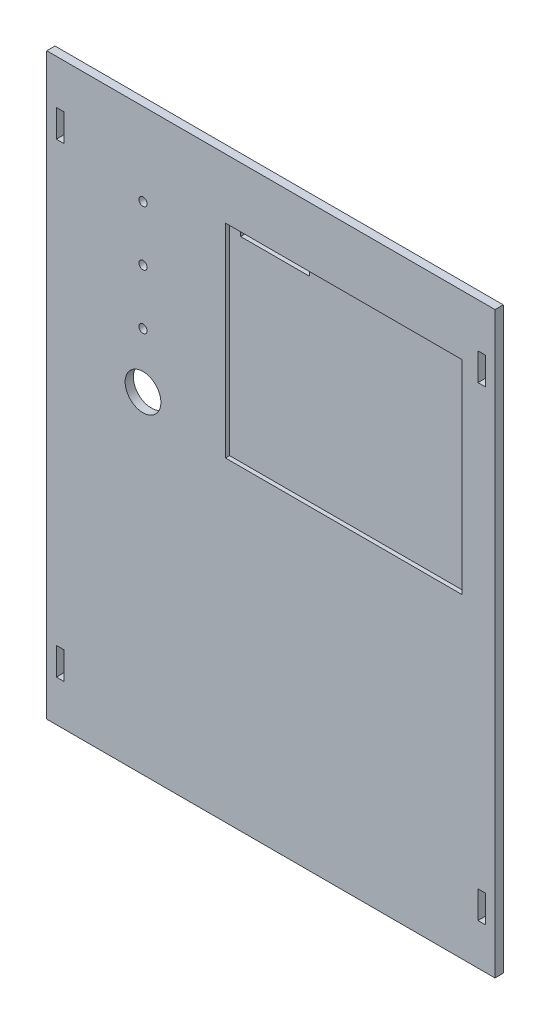
from build123d import *

# Parameters (mm, degrees)
SKETCH1_W           = 163
SKETCH1_H           = 210.5
BOSS_EXTRUDE1_DEPTH = 3
SKETCH2_W           = 2.7
SKETCH2_H           = 10
CUT_EXTRUDE1_DEPTH  = 3
SKETCH3_W           = 86
SKETCH3_H           = 74
CUT_EXTRUDE2_DEPTH  = 1.5
CUT_EXTRUDE3_REACH  = 3.5
SKETCH4_W           = 25
SKETCH4_H           = 3
CUT_EXTRUDE5_REACH  = 5
SKETCH5_R           = 1.5
SKETCH5_R_2         = 6.5


with BuildPart() as part:
    # Sketch1 → Boss-Extrude1 (new body)
    with BuildSketch(Plane.XY):
        Rectangle(SKETCH1_W, SKETCH1_H)
    extrude(amount=BOSS_EXTRUDE1_DEPTH)

    # Sketch2 → Cut-Extrude1 (cut)
    with BuildSketch(Plane.XY.offset(3)):
        with Locations((-76.65, -85.25)):
            Rectangle(SKETCH2_W, SKETCH2_H)
        with Locations((-76.65, 84.15)):
            Rectangle(SKETCH2_W, SKETCH2_H)
    cut_extrude1 = extrude(amount=-CUT_EXTRUDE1_DEPTH, mode=Mode.SUBTRACT)

    # Mirror3: Cut-Extrude1 across plane
    add(cut_extrude1.mirror(Plane(origin=(0, 0, 0), x_dir=(0, 0, 1), z_dir=(1, 0, 0))), mode=Mode.SUBTRACT)

    # Sketch3 → Cut-Extrude2 (cut)
    with BuildSketch(Plane.XY.offset(3)):
        with Locations((26.5, 46.5)):
            Rectangle(SKETCH3_W, SKETCH3_H)
    extrude(amount=-CUT_EXTRUDE2_DEPTH, mode=Mode.SUBTRACT)

    # Sketch4 → Cut-Extrude3 (cut, up to next)
    with BuildSketch(Plane.XY.offset(1.5), mode=Mode.PRIVATE) as cut_extrude3_sk1:
        with Locations((0, 82)):
            Rectangle(SKETCH4_W, SKETCH4_H)
    cut_extrude3_tool1 = extrude(cut_extrude3_sk1.sketch, amount=-CUT_EXTRUDE3_REACH, mode=Mode.PRIVATE) & part.part
    add(cut_extrude3_tool1.solids().sort_by_distance((0, 82, 1.5))[0], mode=Mode.SUBTRACT)

    # Sketch5 → Cut-Extrude5 (cut, up to next)
    with BuildSketch(Plane.XY.offset(3), mode=Mode.PRIVATE) as cut_extrude5_sk1:
        with Locations((-46.5, 75.25)):
            Circle(SKETCH5_R)
    cut_extrude5_tool1 = extrude(cut_extrude5_sk1.sketch, amount=-CUT_EXTRUDE5_REACH, mode=Mode.PRIVATE) & part.part
    add(cut_extrude5_tool1.solids().sort_by_distance((-46.5, 75.25, 3))[0], mode=Mode.SUBTRACT)
    # Sketch5 → Cut-Extrude5 (cut, up to next)
    with BuildSketch(Plane.XY.offset(3), mode=Mode.PRIVATE) as cut_extrude5_sk2:
        with Locations((-46.5, 55.25)):
            Circle(SKETCH5_R)
    cut_extrude5_tool2 = extrude(cut_extrude5_sk2.sketch, amount=-CUT_EXTRUDE5_REACH, mode=Mode.PRIVATE) & part.part
    add(cut_extrude5_tool2.solids().sort_by_distance((-46.5, 55.25, 3))[0], mode=Mode.SUBTRACT)
    # Sketch5 → Cut-Extrude5 (cut, up to next)
    with BuildSketch(Plane.XY.offset(3), mode=Mode.PRIVATE) as cut_extrude5_sk3:
        with Locations((-46.5, 35.25)):
            Circle(SKETCH5_R)
    cut_extrude5_tool3 = extrude(cut_extrude5_sk3.sketch, amount=-CUT_EXTRUDE5_REACH, mode=Mode.PRIVATE) & part.part
    add(cut_extrude5_tool3.solids().sort_by_distance((-46.5, 35.25, 3))[0], mode=Mode.SUBTRACT)
    # Sketch5 → Cut-Extrude5 (cut, up to next)
    with BuildSketch(Plane.XY.offset(3), mode=Mode.PRIVATE) as cut_extrude5_sk4:
        with Locations((-46.5, 15.25)):
            Circle(SKETCH5_R_2)
    cut_extrude5_tool4 = extrude(cut_extrude5_sk4.sketch, amount=-CUT_EXTRUDE5_REACH, mode=Mode.PRIVATE) & part.part
    add(cut_extrude5_tool4.solids().sort_by_distance((-46.5, 15.25, 3))[0], mode=Mode.SUBTRACT)


solid = part.part
